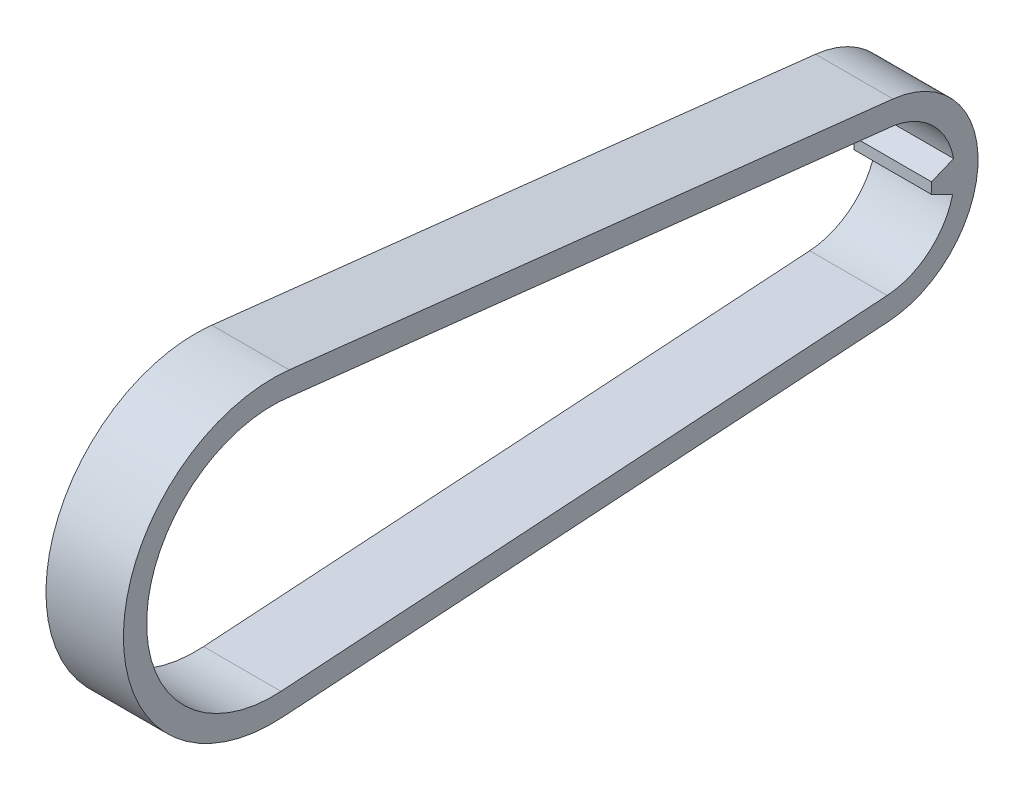
from build123d import *

# Parameters (mm, degrees)
BOSS_EXTRUDE1_DEPTH = 10
BOSS_EXTRUDE2_DEPTH = 10


with BuildPart() as part:
    # Sketch1 → Boss-Extrude1 (new body)
    with BuildSketch(Plane(origin=(0, 0, 0), x_dir=(0, 0, -1), z_dir=(1, 0, 0))):
        with BuildLine():
            Line((-76.592461771, 20.953089015), (1.366493243, 12.273096648))
            ThreePointArc((1.366493243, 12.273096648), (12.345744217, -0.280722022), (0.807229086, -12.322523537))
            Line((0.807229086, -12.322523537), (-77.465686513, -17.45005881))
            ThreePointArc((-77.465686513, -17.45005881), (-98.002496493, 2.228416408), (-76.592461771, 20.953089015))
        make_face()
        with BuildLine():
            Line((-77.661791455, -14.456475197), (0.611124144, -9.328939923))
            ThreePointArc((0.611124144, -9.328939923), (9.339609214, -0.417483589), (1.441037018, 9.237207648))
            Line((1.441037018, 9.237207648), (-76.216477855, 17.876925629))
            ThreePointArc((-76.216477855, 17.876925629), (-94.991237369, 2.517160117), (-77.661791455, -14.456475197))
        make_face(mode=Mode.SUBTRACT)
    extrude(amount=BOSS_EXTRUDE1_DEPTH)

    # Sketch2 → Boss-Extrude2 (add)
    with BuildSketch(Plane.ZY):
        with BuildLine():
            Line((-6.336674596, 0.518546587), (-9.195436771, 1.687167861))
            ThreePointArc((-9.195436771, 1.687167861), (-9.3441708, -0.298437374), (-9.069035243, -2.270504914))
            Line((-9.069035243, -2.270504914), (-6.299160688, -0.86192234))
            Line((-6.299160688, -0.86192234), (-6.336674596, 0.518546587))
        make_face()
    extrude(amount=-BOSS_EXTRUDE2_DEPTH)


solid = part.part
